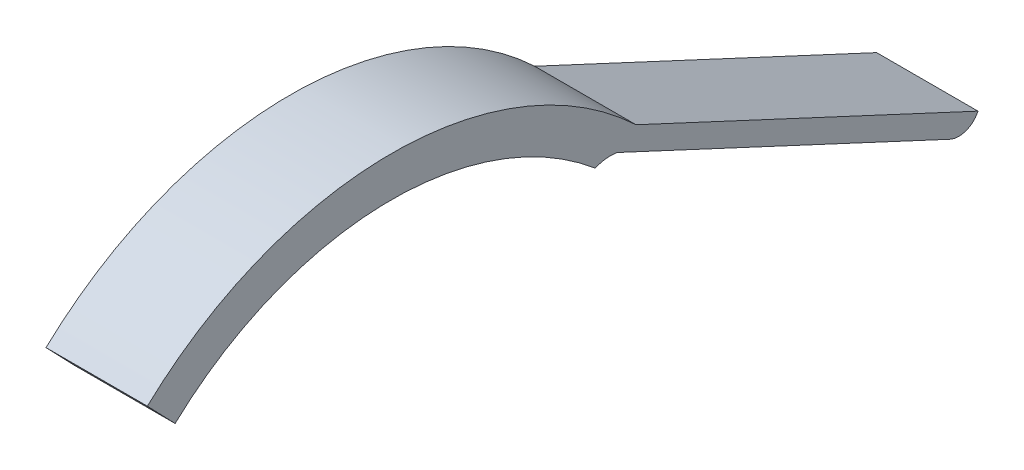
from build123d import *

# Parameters (mm, degrees)
BOSS_EXTRUDE1_DEPTH = 4.3


with BuildPart() as part:
    # Sketch1 → Boss-Extrude1 (new body)
    with BuildSketch(Plane(origin=(0, 0, 0), x_dir=(0, 0, -1), z_dir=(1, 0, 0))):
        with BuildLine():
            Line((10.377941535, 10.968515373), (24.883087867, 4.215684123))
            ThreePointArc((24.883087867, 4.215684123), (24.37551983, 3.75), (23.687326628, 3.7796164))
            Line((23.687326628, 3.7796164), (9.577602267, 10.348360032))
            ThreePointArc((9.577602267, 10.348360032), (9.104252866, 10.361422213), (8.647588121, 10.236172121))
            ThreePointArc((8.647588121, 10.236172121), (-0.351285356, 13.395394679), (-9.172206838, 9.768859797))
            Line((-9.172206838, 9.768859797), (-10.349710711, 10.995157488))
            ThreePointArc((-10.349710711, 10.995157488), (0.019408643, 15.099987527), (10.377941535, 10.968515373))
        make_face()
    extrude(amount=BOSS_EXTRUDE1_DEPTH)


solid = part.part
